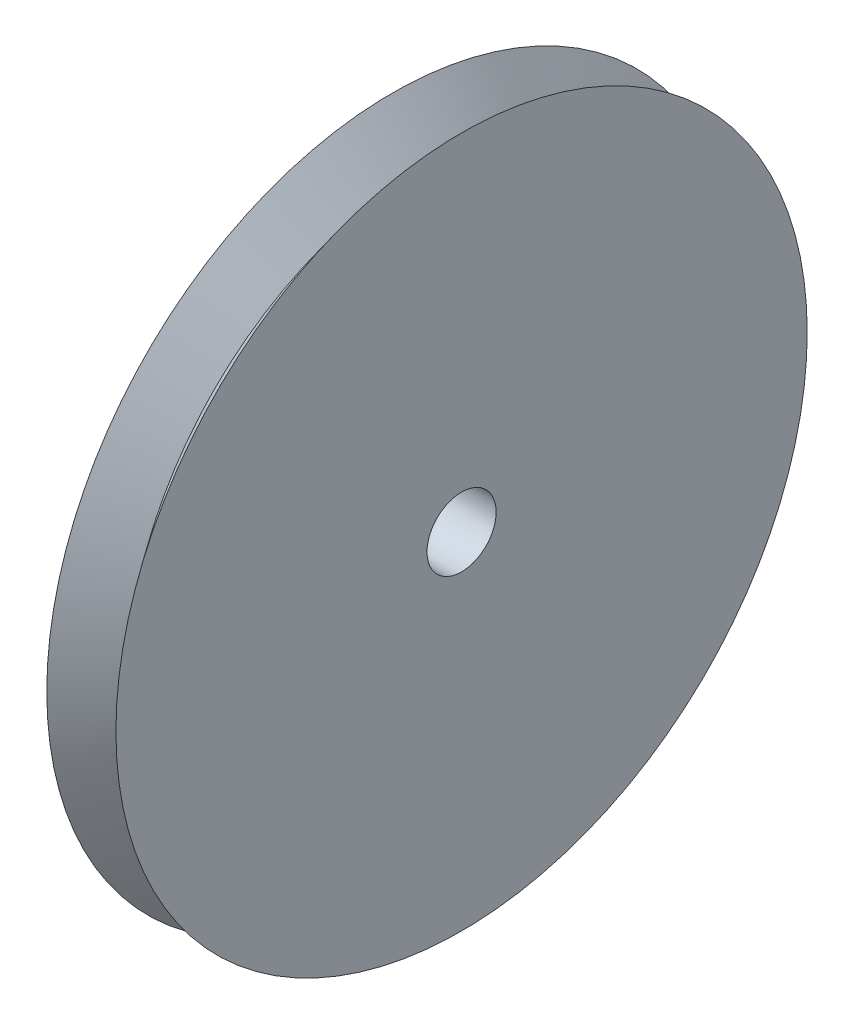
from build123d import *

# Parameters (mm, degrees)
SKETCH2_R          = 2.54
CUT_EXTRUDE1_DEPTH = 6.08


with BuildPart() as part:
    # Sketch1 → Revolve1 (revolve)
    with BuildSketch(Plane(origin=(0, 0, 0), x_dir=(1, 0, 0), z_dir=(0, 1, 0))):
        Polygon((2.54, 22.098), (5.08, 25.4), (5.08, 0), (0, 0), (0, 25.4), align=None)
    revolve(axis=Axis((0, 0, 0), (1, 0, 0)))

    # Sketch2 → Cut-Extrude1 (cut, through all)
    with BuildSketch(Plane(origin=(5.08, 0, 0), x_dir=(0, 0, -1), z_dir=(1, 0, 0))):
        Circle(SKETCH2_R)
    extrude(amount=-CUT_EXTRUDE1_DEPTH, mode=Mode.SUBTRACT)


solid = part.part
